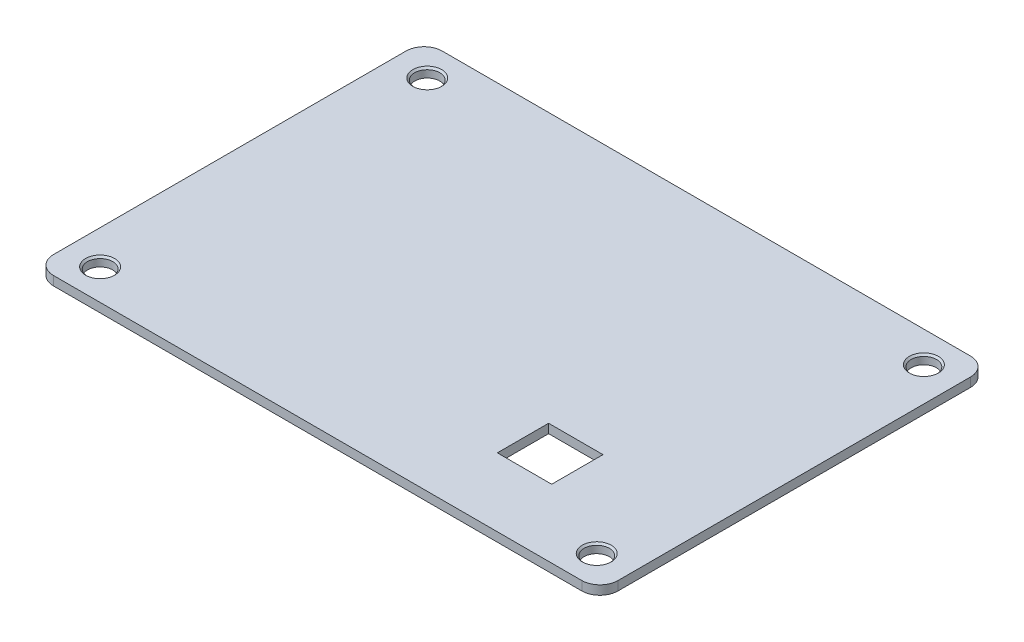
from build123d import *

# Parameters (mm, degrees)
SZKIC1_W                    = 62.3
SZKIC1_H                    = 42.9
DODANIE_WYCI_GNI_CIE1_DEPTH = 1
SZKIC5_W                    = 6
SZKIC5_H                    = 5.66
WYTNIJ_WYCI_GNI_CIE2_DEPTH  = 7
SZKIC6_R                    = 1.4
WYTNIJ_WYCI_GNI_CIE3_DEPTH  = 10
ZAOKR_GLENIE1_R             = 2
SFAZOWANIE1_SIZE            = 0.2


with BuildPart() as part:
    # Szkic1 → Dodanie-wyciągnięcie1 (new body)
    with BuildSketch(Plane(origin=(0, 0, 0), x_dir=(1, 0, 0), z_dir=(0, 1, 0))):
        Rectangle(SZKIC1_W, SZKIC1_H)
    extrude(amount=DODANIE_WYCI_GNI_CIE1_DEPTH)

    # Szkic5 → Wytnij-wyciągnięcie2 (cut)
    with BuildSketch(Plane(origin=(0, 1, 0), x_dir=(1, 0, 0), z_dir=(0, 1, 0))):
        with Locations((15.29, -11.08)):
            Rectangle(SZKIC5_W, SZKIC5_H)
    extrude(amount=-WYTNIJ_WYCI_GNI_CIE2_DEPTH, mode=Mode.SUBTRACT)

    # Szkic6 → Wytnij-wyciągnięcie3 (cut)
    with BuildSketch(Plane(origin=(0, 1, 0), x_dir=(1, 0, 0), z_dir=(0, 1, 0))):
        with Locations((27.4, 18.05)):
            Circle(SZKIC6_R)
        with Locations((27.4, -18.05)):
            Circle(SZKIC6_R)
        with Locations((-27.4, -18.05)):
            Circle(SZKIC6_R)
        with Locations((-27.4, 18.05)):
            Circle(SZKIC6_R)
    extrude(amount=-WYTNIJ_WYCI_GNI_CIE3_DEPTH, mode=Mode.SUBTRACT)

    # Zaokrąglenie1
    zaokr_glenie1_edges = [part.edges().sort_by_distance(p)[0] for p in [
        (31.15, 0.5, 21.45),
        (-31.15, 0.5, 21.45),
        (-31.15, 0.5, -21.45),
        (31.15, 0.5, -21.45),
    ]]
    fillet(zaokr_glenie1_edges, radius=ZAOKR_GLENIE1_R)

    # Sfazowanie1
    sfazowanie1_edges = [part.edges().sort_by_distance(p)[0] for p in [
        (-28.8, 1, -18.05),
        (-28.8, 1, 18.05),
        (26, 1, 18.05),
        (26, 1, -18.05),
    ]]
    chamfer(sfazowanie1_edges, length=SFAZOWANIE1_SIZE)


solid = part.part
